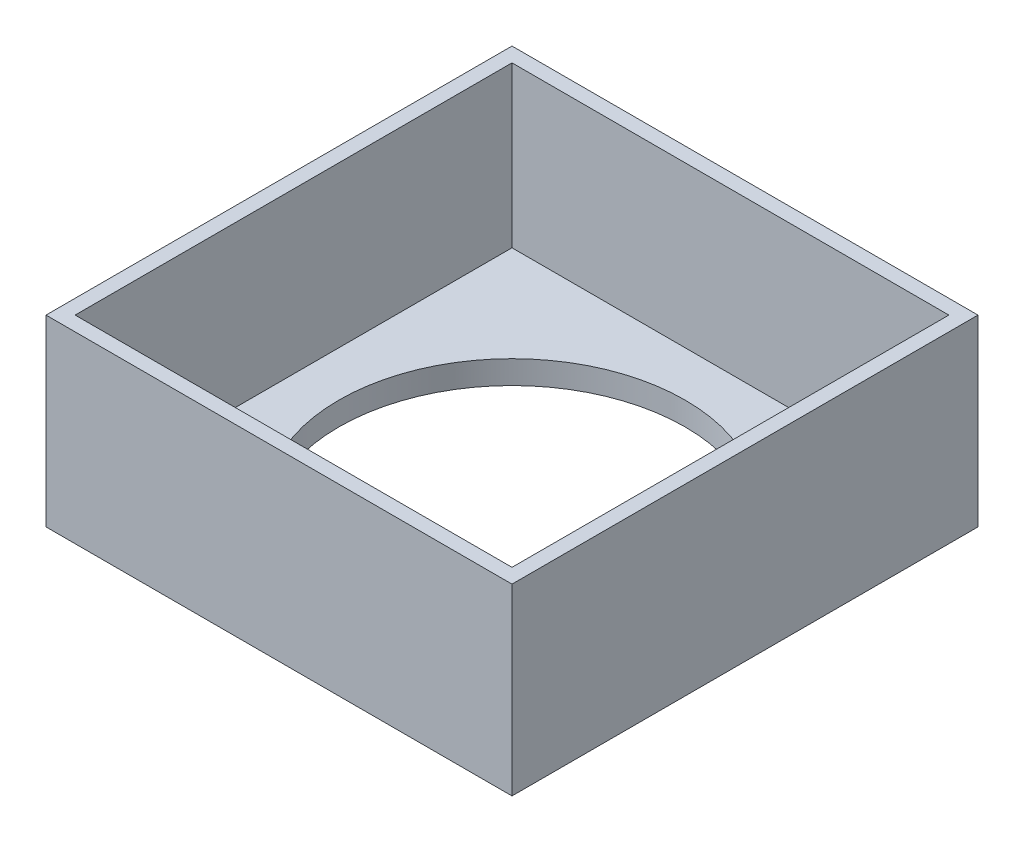
from build123d import *

# Parameters (mm, degrees)
SKETCH1_W           = 203.2
SKETCH1_H           = 203.2
BOSS_EXTRUDE1_DEPTH = 80
SKETCH3_R           = 75.5
CUT_EXTRUDE1_DEPTH  = 80
SKETCH4_W           = 190.5
SKETCH4_H           = 190.5
CUT_EXTRUDE2_DEPTH  = 69.85


with BuildPart() as part:
    # Sketch1 → Boss-Extrude1 (new body)
    with BuildSketch(Plane(origin=(0, 0, 0), x_dir=(1, 0, 0), z_dir=(0, 1, 0))):
        Rectangle(SKETCH1_W, SKETCH1_H)
    extrude(amount=BOSS_EXTRUDE1_DEPTH)

    # Sketch3 → Cut-Extrude1 (cut)
    with BuildSketch(Plane(origin=(0, 80, 0), x_dir=(1, 0, 0), z_dir=(0, 1, 0))):
        Circle(SKETCH3_R)
    extrude(amount=-CUT_EXTRUDE1_DEPTH, mode=Mode.SUBTRACT)

    # Sketch4 → Cut-Extrude2 (cut)
    with BuildSketch(Plane(origin=(0, 80, 0), x_dir=(1, 0, 0), z_dir=(0, 1, 0))):
        Rectangle(SKETCH4_W, SKETCH4_H)
    extrude(amount=-CUT_EXTRUDE2_DEPTH, mode=Mode.SUBTRACT)


solid = part.part
